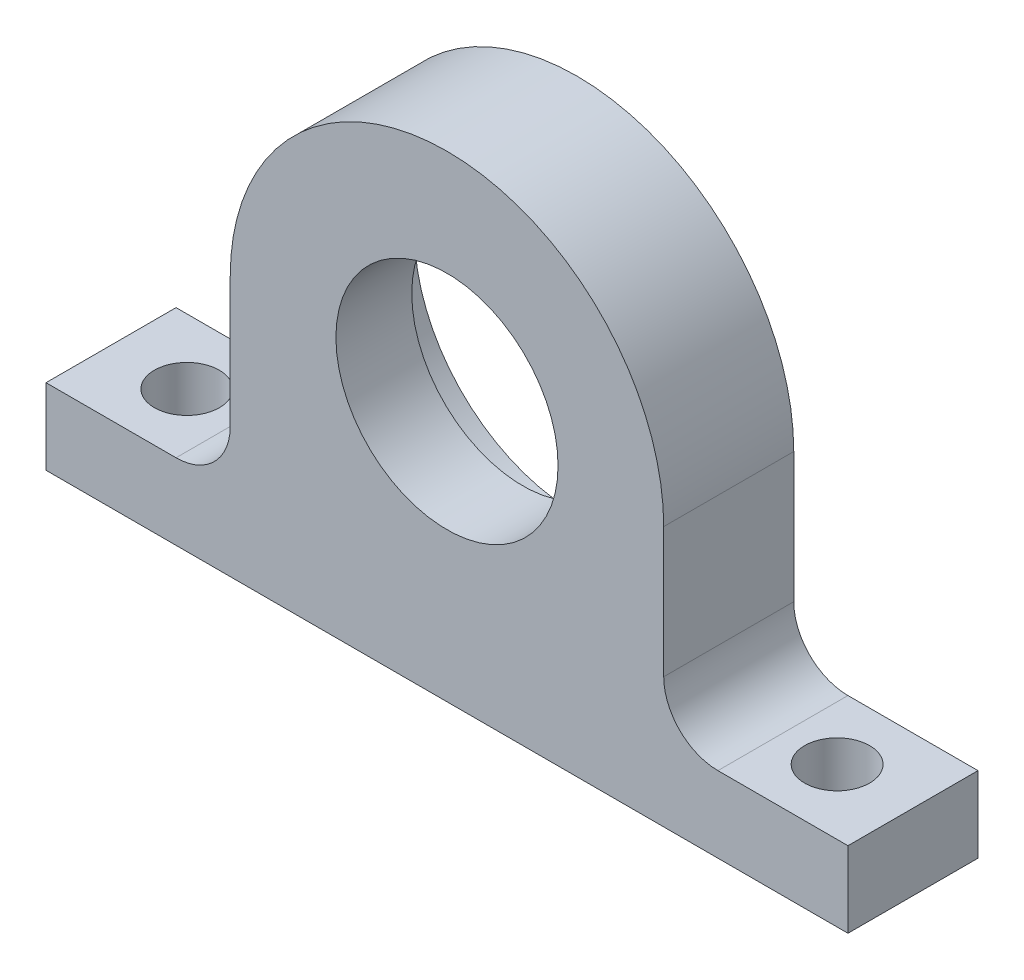
from build123d import *

# Parameters (mm, degrees)
SKETCH1_R           = 10.25
BOSS_EXTRUDE1_DEPTH = 12
SKETCH2_R           = 3
CUT_EXTRUDE1_DEPTH  = 8
SKETCH3_R           = 15
CUT_EXTRUDE2_DEPTH  = 5
BOSS_EXTRUDE2_DEPTH = 12
FILLET2_R           = 5


with BuildPart() as part:
    # Sketch1 → Boss-Extrude1 (new body)
    with BuildSketch(Plane.XY):
        with BuildLine():
            Line((-10.535653753, -17), (-37, -17))
            Line((-37, -17), (-37, -24))
            Line((-37, -24), (0, -24))
            Line((0, -24), (37, -24))
            Line((37, -24), (37, -17))
            Line((37, -17), (10.535653753, -17))
            ThreePointArc((10.535653753, -17), (0, 20), (-10.535653753, -17))
        make_face()
        Circle(SKETCH1_R, mode=Mode.SUBTRACT)
    extrude(amount=BOSS_EXTRUDE1_DEPTH)

    # Sketch2 → Cut-Extrude1 (cut, through all)
    with BuildSketch(Plane(origin=(0, -17, 0), x_dir=(1, 0, 0), z_dir=(0, 1, 0))):
        with Locations((30, -6)):
            Circle(SKETCH2_R)
        with Locations((-30, -6)):
            Circle(SKETCH2_R)
    extrude(amount=-CUT_EXTRUDE1_DEPTH, mode=Mode.SUBTRACT)

    # Sketch3 → Cut-Extrude2 (cut)
    with BuildSketch(Plane(origin=(0, 0, 0), x_dir=(-1, 0, 0), z_dir=(0, 0, -1))):
        Circle(SKETCH3_R)
    extrude(amount=-CUT_EXTRUDE2_DEPTH, mode=Mode.SUBTRACT)

    # Sketch4 → Boss-Extrude2 (add, through all)
    with BuildSketch(Plane(origin=(0, 0, 0), x_dir=(-1, 0, 0), z_dir=(0, 0, -1))):
        Polygon((-20, 0), (-10.535653753, -17), (-20, -17), align=None)
        Polygon((20, 0), (20, -17), (10.535653753, -17), align=None)
    extrude(amount=-BOSS_EXTRUDE2_DEPTH)

    # Fillet2
    fillet2_edges = [part.edges().sort_by_distance(p)[0] for p in [
        (-20, -17, 6),
        (20, -17, 6),
    ]]
    fillet(fillet2_edges, radius=FILLET2_R)


solid = part.part
